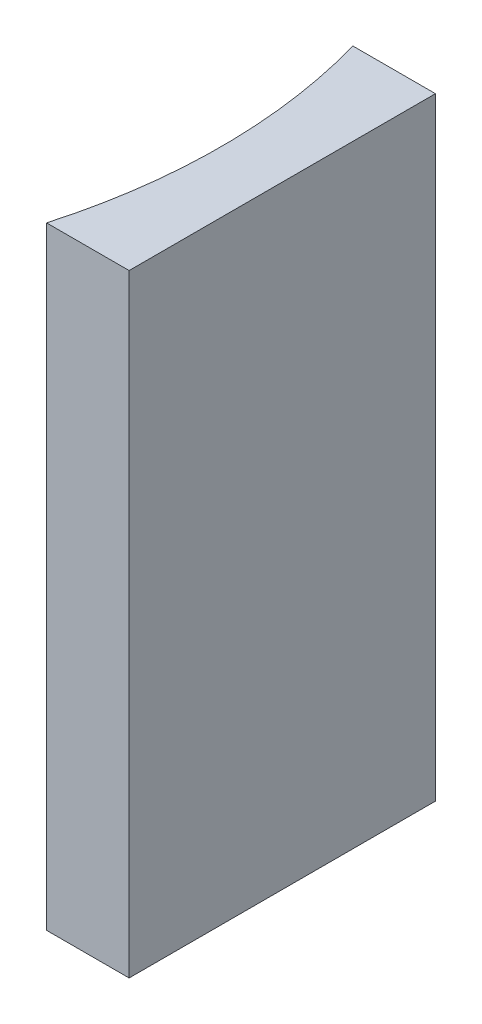
from build123d import *

# Parameters (mm, degrees)
EXTRUDE_1_DEPTH = 20


with BuildPart() as part:
    # 草图1 → 凸台-拉伸1 (new body)
    with BuildSketch(Plane(origin=(0, 0, 0), x_dir=(1, 0, 0), z_dir=(0, 1, 0))):
        with BuildLine():
            Line((0, 0), (0, -10))
            Line((0, -10), (-2.695517029, -10))
            ThreePointArc((-2.695517029, -10), (-2, -5), (-2.695517029, 0))
            Line((-2.695517029, 0), (0, 0))
        make_face()
    extrude(amount=EXTRUDE_1_DEPTH)


solid = part.part
